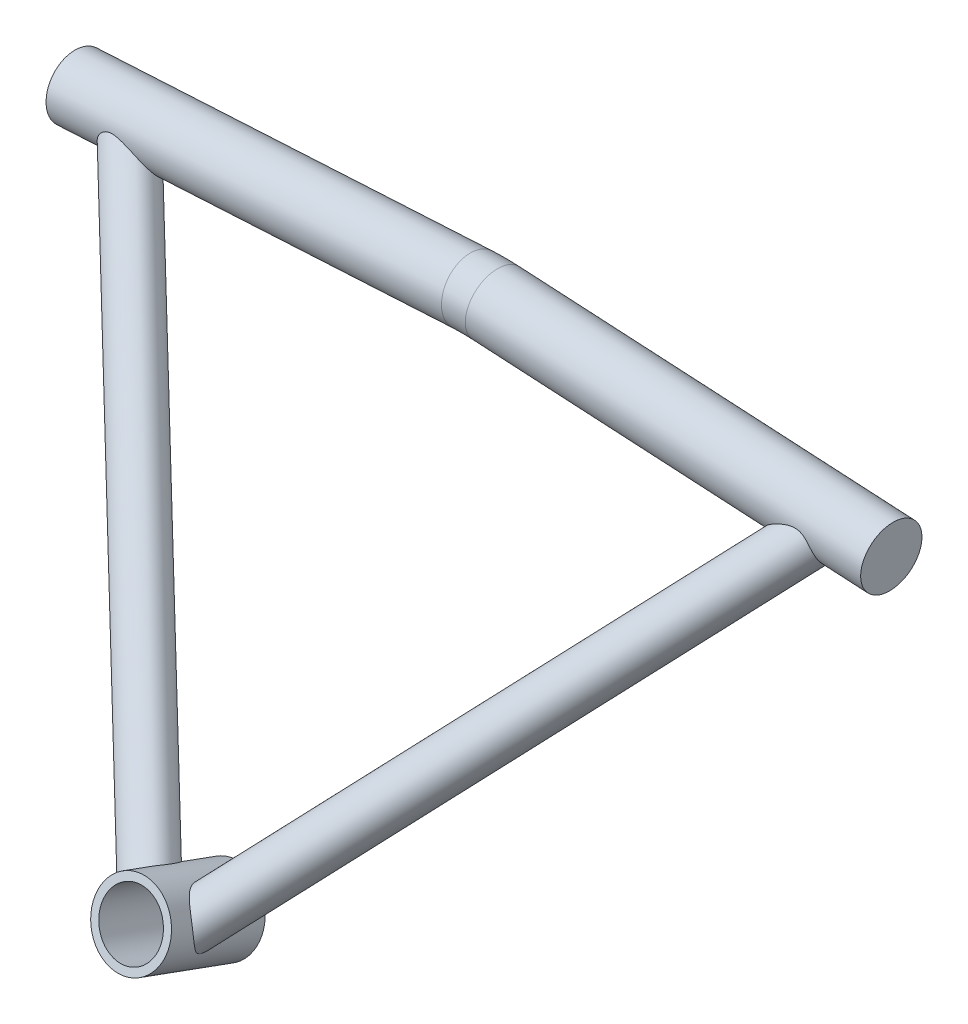
from build123d import *

# Parameters (mm, degrees)
SKETCH1_R               = 15.875
BOSS_EXTRUDE1_DEPTH     = 20.701
SWEEP1_PROFILE_R        = 9.525
SWEEP2_PROFILE_R        = 9.525
CUT_EXTRUDE2_REACH      = 371.805
SKETCH36_R              = 7.9375
CUT_EXTRUDE3_REACH      = 371.805
CUT_EXTRUDE3_END_RADIUS = 15.875
SKETCH37_R              = 7.9375
SKETCH77_R              = 15.875
BOSS_EXTRUDE2_DEPTH     = 41.402
CUT_EXTRUDE1_REACH      = 251.445
SKETCH2_R               = 12.7
SWEEP3_PROFILE_R        = 12.7


with BuildPart() as part:
    # Sketch1 → Boss-Extrude1 (new, symmetric)
    with BuildSketch(Plane(origin=(0, 0, 0), x_dir=(1, 0, 0), z_dir=(0, 0.34202014332566943, 0.9396926207859081))):
        with Locations(Location((0, 0, 0), (0, 0, 270))):
            Circle(SKETCH1_R)
    extrude(amount=BOSS_EXTRUDE1_DEPTH, both=True)

    # Sweep1: sweep along a path in Sketch4
    with BuildLine(Plane(origin=(0, 3.144101118, 3.616874596), x_dir=(1, 0, 0), z_dir=(0, 0.6560590289905084, 0.754709580222771))) as sweep1_path:
        Line((-5.08, -4.165974834), (-143.483994092, 193.495413453))
    # Sweep1 profile (on start of the path) → Sweep1 (sweep)
    with BuildSketch(Plane(origin=(-5.08, 0, 6.35), x_dir=(0.7330812283825076, 0.6801410975622587, 0), z_dir=(-0.5735764363510472, 0.6182218954839692, -0.5374120947718255))):
        Circle(SWEEP1_PROFILE_R)
    sweep(path=sweep1_path.line)

    # Sweep2: sweep along a path in Sketch15
    with BuildLine(Plane(origin=(0, 3.144101118, 3.616874596), x_dir=(1, 0, 0), z_dir=(0, 0.6560590289905084, 0.754709580222771))) as sweep2_path:
        Line((5.08, -4.165974834), (143.483994092, 193.495413453))
    # Sweep2 profile (on start of the path) → Sweep2 (sweep)
    with BuildSketch(Plane(origin=(5.08, 0, 6.35), x_dir=(0.7330812283825074, -0.6801410975622589, 0), z_dir=(0.5735764363510474, 0.6182218954839692, -0.5374120947718254))):
        Circle(SWEEP2_PROFILE_R)
    sweep(path=sweep2_path.line)

    # Sketch36 → Cut-Extrude2 (cut, up to next)
    with BuildSketch(Plane(origin=(-138.117895022, 148.868575223, -129.409478119), x_dir=(0.819110877584774, 0.4394391101382058, -0.36871484741361205), z_dir=(-0.5735764363510473, 0.6182218954839692, -0.5374120947718255)), mode=Mode.PRIVATE) as cut_extrude2_sk1:
        with Locations(Location((-6.502422539, -4.857839146, 0), (0, 0, 154.073467295))):
            Circle(SKETCH36_R)
    cut_extrude2_tool1 = extrude(cut_extrude2_sk1.sketch, amount=-CUT_EXTRUDE2_REACH, mode=Mode.PRIVATE) & part.part
    add(cut_extrude2_tool1.solids().sort_by_distance((-143.483994, 149.176943, -123.327538))[0], mode=Mode.SUBTRACT)

    # Cut-Extrude3: up to this cylinder (the profile starts outside it)
    cut_extrude3_end = Plane(origin=(0, -22.186319293, -60.956411279), z_dir=(0, -0.34202014332566943, -0.9396926207859081)) * Cylinder(CUT_EXTRUDE3_END_RADIUS, 776.36, mode=Mode.PRIVATE)
    # Sketch37 → Cut-Extrude3 (cut, up to the surface)
    with BuildSketch(Plane(origin=(138.117895022, 148.868575223, -129.409478119), x_dir=(0.8191108775847737, -0.4394391101382061, 0.36871484741361227), z_dir=(0.5735764363510476, 0.6182218954839689, -0.5374120947718255)), mode=Mode.PRIVATE) as cut_extrude3_sk1:
        with Locations(Location((6.502422539, -4.857839146, 0), (0, 0, 205.926532705))):
            Circle(SKETCH37_R)
    cut_extrude3_tool1 = extrude(cut_extrude3_sk1.sketch, amount=-CUT_EXTRUDE3_REACH, mode=Mode.PRIVATE) - cut_extrude3_end
    add(cut_extrude3_tool1.solids().sort_by_distance((143.483994, 149.176943, -123.327538))[0], mode=Mode.SUBTRACT)

    # Sketch77 → Boss-Extrude2 (add)
    with BuildSketch(Plane(origin=(0, 7.080158987, 19.452576943), x_dir=(1, 0, 0), z_dir=(0, 0.34202014332566943, 0.9396926207859082))):
        with Locations(Location((0, 0, 0), (0, 0, 270))):
            Circle(SKETCH77_R)
    extrude(amount=-BOSS_EXTRUDE2_DEPTH)

    # Sketch2 → Cut-Extrude1 (cut, up to next)
    with BuildSketch(Plane(origin=(0, -7.080158987, -19.452576943), x_dir=(-1, 0, 0), z_dir=(0, -0.34202014332566943, -0.9396926207859081)), mode=Mode.PRIVATE) as cut_extrude1_sk1:
        with Locations(Location((0, 0, 0), (0, 0, 90))):
            Circle(SKETCH2_R)
    cut_extrude1_tool1 = extrude(cut_extrude1_sk1.sketch, amount=-CUT_EXTRUDE1_REACH, mode=Mode.PRIVATE) & part.part
    add(cut_extrude1_tool1.solids().sort_by_distance((0, -7.080159, -19.452577))[0], mode=Mode.SUBTRACT)

    # Sweep3: sweep along a path in Sketch40
    with BuildLine(Plane(origin=(-106.934, 0, -127), x_dir=(1, 0, 0), z_dir=(0, 0, 1))) as sweep3_path:
        Line((-62.089448271, 150.498042412), (101.994706052, 159.628680082))
        ThreePointArc((101.994706052, 159.628680082), (106.934, 159.766), (111.873293948, 159.628680082))
        Line((111.873293948, 159.628680082), (275.957448271, 150.498042412))
    # Sweep3 profile (on start of the path) → Sweep3 (sweep)
    with BuildSketch(Plane(origin=(-169.023448271, 150.498042412, -127), x_dir=(-0.0555601119023539, 0.9984553440016224, 0), z_dir=(0.9984553440016224, 0.0555601119023539, 0))):
        Circle(SWEEP3_PROFILE_R)
    sweep(path=sweep3_path.line)


solid = part.part
